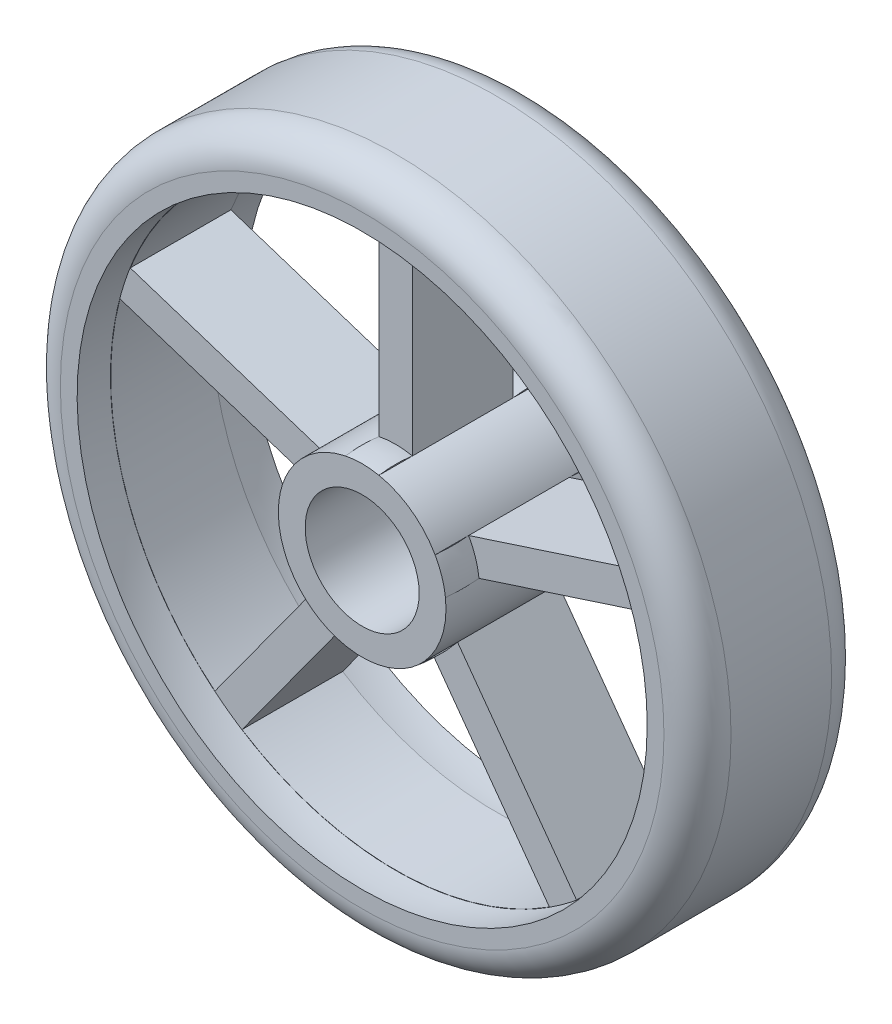
from build123d import *

# Parameters (mm, degrees)
SKETCH1_R           = 20
SKETCH1_R_2         = 3.4
BOSS_EXTRUDE4_DEPTH = 10
FILLET1_R           = 2


with BuildPart() as part:
    # Sketch1 → Boss-Extrude4 (new body)
    with BuildSketch(Plane.XY):
        Circle(SKETCH1_R)
        with BuildLine():
            ThreePointArc((-4.968223357, 0.5628114), (-4.755282581, -1.545084972), (-3.688564887, -3.375572407))
            Line((-3.688564887, -3.375572407), (-10.784063501, -13.141688415))
            ThreePointArc((-10.784063501, -13.141688415), (-16.167960777, -5.253288904), (-16.448981282, 4.293135777))
            Line((-16.448981282, 4.293135777), (-4.968223357, 0.5628114))
        make_face(mode=Mode.SUBTRACT)
        with BuildLine():
            ThreePointArc((-1, 4.898979486), (-2.938926261, 4.045084972), (-4.350189369, 2.464924432))
            Line((-4.350189369, 2.464924432), (-15.830947293, 6.19524881))
            ThreePointArc((-15.830947293, 6.19524881), (-9.992349289, 13.753288904), (-1, 16.970562748))
            Line((-1, 16.970562748), (-1, 4.898979486))
        make_face(mode=Mode.SUBTRACT)
        with BuildLine():
            ThreePointArc((4.350189369, 2.464924432), (2.938926261, 4.045084972), (1, 4.898979486))
            Line((1, 4.898979486), (1, 16.970562748))
            ThreePointArc((1, 16.970562748), (9.992349289, 13.753288904), (15.830947293, 6.19524881))
            Line((15.830947293, 6.19524881), (4.350189369, 2.464924432))
        make_face(mode=Mode.SUBTRACT)
        with BuildLine():
            Line((4.968223357, 0.5628114), (16.448981282, 4.293135777))
            ThreePointArc((16.448981282, 4.293135777), (16.167960777, -5.253288904), (10.784063501, -13.141688415))
            Line((10.784063501, -13.141688415), (3.688564887, -3.375572407))
            ThreePointArc((3.688564887, -3.375572407), (4.755282581, -1.545084972), (4.968223357, 0.5628114))
        make_face(mode=Mode.SUBTRACT)
        with BuildLine():
            ThreePointArc((-2.070530899, -4.551142911), (0, -5), (2.070530899, -4.551142911))
            Line((2.070530899, -4.551142911), (9.166029512, -14.31725892))
            ThreePointArc((9.166029512, -14.31725892), (0, -17), (-9.166029512, -14.31725892))
            Line((-9.166029512, -14.31725892), (-2.070530899, -4.551142911))
        make_face(mode=Mode.SUBTRACT)
        Circle(SKETCH1_R_2, mode=Mode.SUBTRACT)
    extrude(amount=BOSS_EXTRUDE4_DEPTH)

    # Fillet1
    fillet1_edges = [part.edges().sort_by_distance(p)[0] for p in [
        (-20, 0, 0),
        (-20, 0, 10),
    ]]
    fillet(fillet1_edges, radius=FILLET1_R)

    # Cut-Sweep1: sweep along a curve in space
    with BuildLine() as cut_sweep1_path:
        ThreePointArc((18, 0, 0), (12.727922061, 12.727922061, 0), (0, 18, 0))
        ThreePointArc((0, 18, 0), (-12.727922061, 12.727922061, 0), (-18, 0, 0))
        ThreePointArc((-18, 0, 0), (-12.727922061, -12.727922061, 0), (0, -18, 0))
        ThreePointArc((0, -18, 0), (12.727922061, -12.727922061, 0), (18, 0, 0))
    # Sketch3 → Cut-Sweep1 (sweep, cut)
    with BuildSketch(Plane(origin=(1, 0, 0), x_dir=(0, 0, -1), z_dir=(1, 0, 0))):
        with BuildLine():
            Line((-10, 16.970562748), (-10, 4.898979486))
            ThreePointArc((-10, 4.898979486), (-9, 4.972910797), (-8, 4.898979486))
            Line((-8, 4.898979486), (-8, 16.980527838))
            ThreePointArc((-8, 16.980527838), (-9.000206246, 17.016938924), (-10, 16.970562748))
        make_face()
        with BuildLine():
            Line((0, 16.970562748), (0, 4.898979486))
            ThreePointArc((0, 4.898979486), (-1, 4.972910797), (-2, 4.898979486))
            Line((-2, 4.898979486), (-2, 16.970562748))
            ThreePointArc((-2, 16.970562748), (-1, 17.011955864), (0, 16.970562748))
        make_face()
    sweep(path=cut_sweep1_path.line, mode=Mode.SUBTRACT)


solid = part.part
